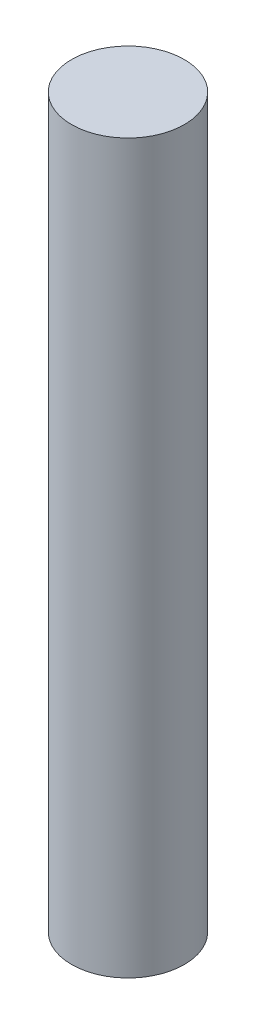
from build123d import *

# Parameters (mm, degrees)
SKETCH_1_R      = 4
EXTRUDE_1_DEPTH = 51.6


with BuildPart() as part:
    # ｽｹｯﾁ1 → ﾎﾞｽ - 押し出し1 (new body)
    with BuildSketch(Plane(origin=(0, 0, 0), x_dir=(1, 0, 0), z_dir=(0, 1, 0))):
        Circle(SKETCH_1_R)
    extrude(amount=EXTRUDE_1_DEPTH)


solid = part.part
